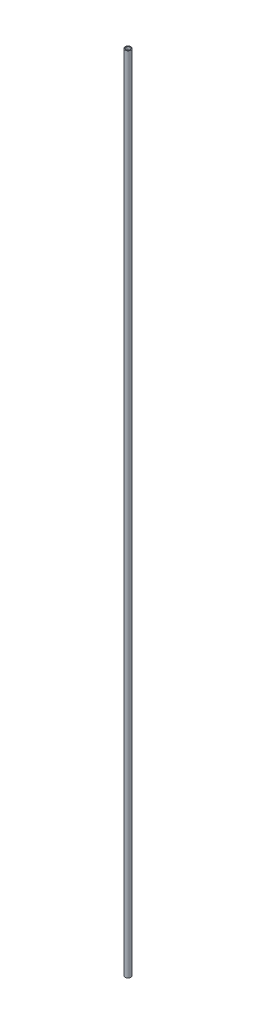
from build123d import *

# Parameters (mm, degrees)
SKETCH1_R           = 0.06604
SKETCH1_R_2         = 0.04826
BOSS_EXTRUDE1_DEPTH = 18


with BuildPart() as part:
    # Sketch1 → Boss-Extrude1 (new body)
    with BuildSketch(Plane(origin=(0, 0, 0), x_dir=(1, 0, 0), z_dir=(0, 1, 0))):
        Circle(SKETCH1_R)
        Circle(SKETCH1_R_2, mode=Mode.SUBTRACT)
    extrude(amount=BOSS_EXTRUDE1_DEPTH)


solid = part.part
